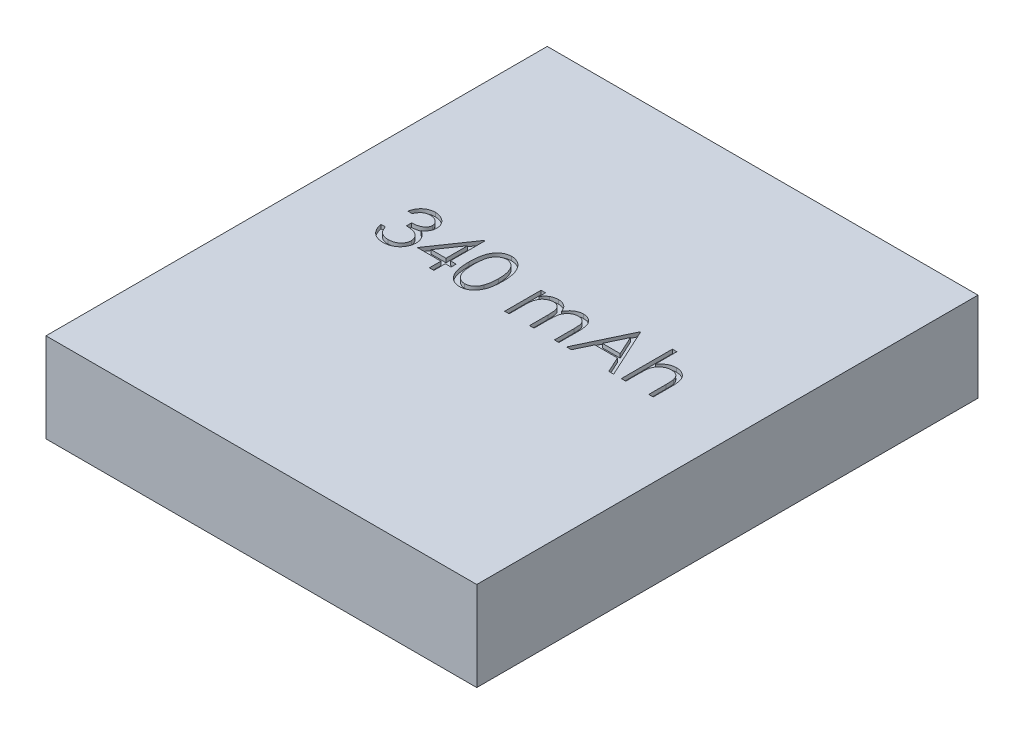
from build123d import *

# Parameters (mm, degrees)
SKETCH1_W           = 27.5
SKETCH1_H           = 32
BOSS_EXTRUDE1_DEPTH = 5.7
CUT_EXTRUDE1_DEPTH  = 0.254


with BuildPart() as part:
    # Sketch1 → Boss-Extrude1 (new body)
    with BuildSketch(Plane(origin=(0, 0, 0), x_dir=(1, 0, 0), z_dir=(0, 1, 0))):
        Rectangle(SKETCH1_W, SKETCH1_H)
    extrude(amount=BOSS_EXTRUDE1_DEPTH)

    # Sketch2 → Cut-Extrude1 (cut)
    with BuildSketch(Plane(origin=(0, 5.7, 0), x_dir=(1, 0, 0), z_dir=(0, 1, 0))):
        with BuildLine():
            Line((6.980929487, 3.256410256), (7.265865385, 3.256410256))
            Line((7.265865385, 3.256410256), (7.265865385, 1.881976162))
            add(Edge.make_bspline(
                [(7.265865385, 1.881976162), (7.296451794, 1.920206774), (7.3560051, 1.994643735), (7.456240863, 2.09176353), (7.559175154, 2.175945136), (7.668363232, 2.242956194), (7.781801918, 2.295893915), (7.899969653, 2.333438423), (8.022888391, 2.356526204), (8.106368348, 2.359427626), (8.148657853, 2.360897436)],
                knots=[0, 0, 0, 0, 0.000146744, 0.000285718, 0.000417826, 0.00054491, 0.000668979, 0.000792481, 0.000915983, 0.001042781, 0.001042781, 0.001042781, 0.001042781], degree=3))
            add(Edge.make_bspline(
                [(8.148657853, 2.360897436), (8.19159328, 2.359314081), (8.275628269, 2.356215074), (8.397985025, 2.331710079), (8.512249533, 2.289838689), (8.618082118, 2.232537173), (8.713173094, 2.16116968), (8.797401094, 2.078772513), (8.866199533, 1.98327403), (8.913007303, 1.895048714), (8.943463181, 1.816545701), (8.962741623, 1.749202579), (8.97908761, 1.674161987), (8.993329513, 1.591462551), (9.002821477, 1.500707288), (9.010445666, 1.402305643), (9.015867163, 1.296263257), (9.016077262, 1.222857031), (9.016185897, 1.184900841)],
                knots=[0, 0, 0, 0, 0.000128741, 0.000251978, 0.000372501, 0.000492599, 0.000611662, 0.000728143, 0.000844672, 0.000963309, 0.001026736, 0.001096978, 0.001173207, 0.001257065, 0.001348583, 0.001446826, 0.001553163, 0.001667017, 0.001667017, 0.001667017, 0.001667017], degree=3))
            Line((9.016185897, 1.184900841), (9.016185897, 0))
            Line((9.016185897, 0), (8.73125, 0))
            Line((8.73125, 0), (8.73125, 1.09140625))
            add(Edge.make_bspline(
                [(8.73125, 1.09140625), (8.731077368, 1.122995386), (8.730747152, 1.183420027), (8.729655546, 1.269930711), (8.727218765, 1.348395062), (8.723281016, 1.418561611), (8.71913963, 1.480528179), (8.713439764, 1.534204779), (8.706808337, 1.579665132), (8.700849514, 1.607028759), (8.698177083, 1.619300881)],
                knots=[0, 0, 0, 0, 9.4769e-05, 0.000181277, 0.000259548, 0.000330249, 0.000392103, 0.000445834, 0.000492159, 0.000529829, 0.000529829, 0.000529829, 0.000529829], degree=3))
            add(Edge.make_bspline(
                [(8.698177083, 1.619300881), (8.687813661, 1.655309249), (8.667890042, 1.724535126), (8.621582234, 1.818571741), (8.563743703, 1.898749328), (8.493125115, 1.96398586), (8.410975742, 2.015159185), (8.316759918, 2.050599245), (8.21136437, 2.072595393), (8.137113392, 2.074808189), (8.09841246, 2.075961538)],
                knots=[0, 0, 0, 0, 0.000112235, 0.000215771, 0.000312707, 0.000407219, 0.000502346, 0.000601207, 0.000707732, 0.000823699, 0.000823699, 0.000823699, 0.000823699], degree=3))
            add(Edge.make_bspline(
                [(8.09841246, 2.075961538), (8.07549098, 2.075529896), (8.030129963, 2.074675687), (7.962866531, 2.06609965), (7.897616595, 2.052085456), (7.833751762, 2.033122053), (7.772625575, 2.007317887), (7.712456309, 1.977445501), (7.654948705, 1.940880156), (7.599081571, 1.899853924), (7.54708638, 1.854433499), (7.498711069, 1.806493761), (7.455587003, 1.755444329), (7.416517638, 1.702104224), (7.382791622, 1.645741811), (7.35335204, 1.586900608), (7.32837323, 1.525503233), (7.315961073, 1.482890142), (7.309750601, 1.46156851)],
                knots=[0, 0, 0, 0, 6.8737e-05, 0.000136029, 0.000203016, 0.000268809, 0.000335543, 0.000401817, 0.000470111, 0.000539693, 0.000609577, 0.000677037, 0.000743816, 0.000809842, 0.000875179, 0.000940599, 0.001007093, 0.001073681, 0.001073681, 0.001073681, 0.001073681], degree=3))
            add(Edge.make_bspline(
                [(7.309750601, 1.46156851), (7.306176978, 1.446128076), (7.298389613, 1.412481469), (7.289939728, 1.356987618), (7.282376156, 1.292502124), (7.275982114, 1.219122793), (7.272060457, 1.136580738), (7.267834767, 1.045439225), (7.266261769, 0.945127349), (7.266001462, 0.875372139), (7.265865385, 0.838907252)],
                knots=[0, 0, 0, 0, 4.7531e-05, 0.000103577, 0.000168266, 0.000242318, 0.000324485, 0.000416151, 0.000516024, 0.000625421, 0.000625421, 0.000625421, 0.000625421], degree=3))
            Line((7.265865385, 0.838907252), (7.265865385, 0))
            Line((7.265865385, 0), (6.980929487, 0))
            Line((6.980929487, 0), (6.980929487, 3.256410256))
        make_face()
        Polygon((5.027083333, 3.175), (6.492467949, 0), (6.182727364, 0), (5.713346354, 1.017628205), (4.274038462, 1.017628205), (3.791301082, 0), (3.480288462, 0), (4.986378205, 3.175), align=None)
        Polygon((5.003550681, 2.556154848), (4.428590745, 1.343269231), (5.563246194, 1.343269231), align=None, mode=Mode.SUBTRACT)
        with BuildLine():
            Line((-0.468108974, 2.320192308), (-0.183173077, 2.320192308))
            Line((-0.183173077, 2.320192308), (-0.183173077, 1.916957131))
            add(Edge.make_bspline(
                [(-0.183173077, 1.916957131), (-0.157515494, 1.952233742), (-0.108353105, 2.019827109), (-0.027739263, 2.108899724), (0.052793354, 2.184490264), (0.110790064, 2.224171297), (0.138651843, 2.243234175)],
                knots=[0, 0, 0, 0, 0.000130766, 0.000250561, 0.000359957, 0.000461102, 0.000461102, 0.000461102, 0.000461102], degree=3))
            add(Edge.make_bspline(
                [(0.138651843, 2.243234175), (0.176629072, 2.261381899), (0.251920024, 2.297360285), (0.371136035, 2.333857871), (0.493123771, 2.35628707), (0.575499794, 2.359354459), (0.616937099, 2.360897436)],
                knots=[0, 0, 0, 0, 0.000126121, 0.000250038, 0.000372801, 0.000497059, 0.000497059, 0.000497059, 0.000497059], degree=3))
            add(Edge.make_bspline(
                [(0.616937099, 2.360897436), (0.644961461, 2.359949208), (0.700420164, 2.358072715), (0.782592875, 2.345862541), (0.862293187, 2.324756798), (0.939050199, 2.295358726), (1.011368244, 2.259756374), (1.077670588, 2.21798271), (1.137201119, 2.171086078), (1.189929752, 2.11694876), (1.237345225, 2.05405056), (1.280959607, 1.980695134), (1.321259621, 1.895235327), (1.343594665, 1.833217108), (1.355353566, 1.800565905)],
                knots=[0, 0, 0, 0, 8.4072e-05, 0.000166375, 0.000248601, 0.000330932, 0.000412566, 0.00049003, 0.000565619, 0.000639381, 0.000716086, 0.000801384, 0.000894984, 0.000999053, 0.000999053, 0.000999053, 0.000999053], degree=3))
            add(Edge.make_bspline(
                [(1.355353566, 1.800565905), (1.367791629, 1.822994486), (1.392267992, 1.867130782), (1.433366677, 1.929595063), (1.47642675, 1.988021224), (1.521815183, 2.042455623), (1.569371772, 2.09262945), (1.619320328, 2.13870859), (1.671376523, 2.180890926), (1.743759483, 2.230169792), (1.837932348, 2.282513007), (1.956666567, 2.327895953), (2.080174222, 2.355941298), (2.164010277, 2.359234474), (2.206345152, 2.360897436)],
                knots=[0, 0, 0, 0, 7.6916e-05, 0.00015136, 0.000224122, 0.000294562, 0.000363845, 0.000431358, 0.000498307, 0.000564639, 0.000693874, 0.000820499, 0.000944881, 0.001071761, 0.001071761, 0.001071761, 0.001071761], degree=3))
            add(Edge.make_bspline(
                [(2.206345152, 2.360897436), (2.245244765, 2.359430386), (2.321375084, 2.356559226), (2.432207318, 2.334013575), (2.535568813, 2.295298852), (2.631251589, 2.242472625), (2.717575134, 2.176088651), (2.792610643, 2.097104777), (2.85590233, 2.006079683), (2.897248667, 1.920452665), (2.925293228, 1.844855613), (2.942584491, 1.780442763), (2.9578605, 1.70954814), (2.970543487, 1.632086974), (2.979813173, 1.547785637), (2.986680894, 1.456782085), (2.99132916, 1.359005591), (2.991657612, 1.291545459), (2.991826923, 1.256770833)],
                knots=[0, 0, 0, 0, 0.000116641, 0.000228278, 0.000337557, 0.000446591, 0.000554977, 0.000662946, 0.000772158, 0.00088622, 0.000947188, 0.001013849, 0.001086078, 0.001164708, 0.001249203, 0.001340422, 0.00143847, 0.001542785, 0.001542785, 0.001542785, 0.001542785], degree=3))
            Line((2.991826923, 1.256770833), (2.991826923, 0))
            Line((2.991826923, 0), (2.706891026, 0))
            Line((2.706891026, 0), (2.706891026, 1.258042869))
            add(Edge.make_bspline(
                [(2.706891026, 1.258042869), (2.706820375, 1.287725104), (2.706684594, 1.344769845), (2.704241086, 1.426641711), (2.699637051, 1.501270864), (2.694253486, 1.568555544), (2.686775173, 1.628652659), (2.677117792, 1.681441496), (2.666887325, 1.727337311), (2.649891105, 1.778215368), (2.622724089, 1.834340488), (2.581342517, 1.894868303), (2.529208921, 1.947555886), (2.469010779, 1.993292502), (2.400477547, 2.030479591), (2.324944548, 2.057037114), (2.24288073, 2.073477153), (2.186072915, 2.075115467), (2.156735777, 2.075961538)],
                knots=[0, 0, 0, 0, 8.9045e-05, 0.00017113, 0.000245678, 0.000313338, 0.000373609, 0.000427253, 0.000474306, 0.000514531, 0.000587924, 0.000660612, 0.000733474, 0.000809288, 0.000886697, 0.000966359, 0.001048684, 0.001136601, 0.001136601, 0.001136601, 0.001136601], degree=3))
            add(Edge.make_bspline(
                [(2.156735777, 2.075961538), (2.120749461, 2.074676881), (2.049626821, 2.072137911), (1.945808415, 2.046217326), (1.846048993, 2.007137384), (1.753325265, 1.950502227), (1.668028627, 1.882640354), (1.594641153, 1.801950363), (1.534014813, 1.710664644), (1.492962992, 1.626167278), (1.467028411, 1.55026714), (1.449904352, 1.483957381), (1.436584418, 1.40859053), (1.424092581, 1.324673021), (1.415939428, 1.231627214), (1.408529547, 1.129883522), (1.405063479, 1.01913593), (1.404578648, 0.942367434), (1.404326923, 0.902509014)],
                knots=[0, 0, 0, 0, 0.000107758, 0.00021297, 0.000319147, 0.000428114, 0.000537576, 0.000645175, 0.000753838, 0.000865349, 0.000925892, 0.00099423, 0.001070573, 0.001155393, 0.001248678, 0.001350681, 0.001461413, 0.001580991, 0.001580991, 0.001580991, 0.001580991], degree=3))
            Line((1.404326923, 0.902509014), (1.404326923, 0))
            Line((1.404326923, 0), (1.119391026, 0))
            Line((1.119391026, 0), (1.119391026, 1.1798127))
            add(Edge.make_bspline(
                [(1.119391026, 1.1798127), (1.11931897, 1.213098782), (1.119180343, 1.277137859), (1.116752541, 1.368971264), (1.112138249, 1.452501958), (1.106803751, 1.527632857), (1.099129161, 1.59422742), (1.090411734, 1.652642665), (1.080116923, 1.702732146), (1.063071813, 1.757671788), (1.037023688, 1.818197197), (0.995124336, 1.882732266), (0.942866031, 1.939218326), (0.881569594, 1.987440905), (0.812621582, 2.027302106), (0.73643664, 2.056022023), (0.653700755, 2.072735486), (0.596661693, 2.074865908), (0.567327724, 2.075961538)],
                knots=[0, 0, 0, 0, 9.9857e-05, 0.000192114, 0.000275552, 0.00035082, 0.000418036, 0.000476595, 0.00052799, 0.000571244, 0.000648997, 0.000724854, 0.000800924, 0.000878799, 0.000958003, 0.00103892, 0.001121993, 0.00120995, 0.00120995, 0.00120995, 0.00120995], degree=3))
            add(Edge.make_bspline(
                [(0.567327724, 2.075961538), (0.53284159, 2.074573193), (0.464111948, 2.071806269), (0.363145161, 2.04690132), (0.265640291, 2.007890481), (0.173152814, 1.953770502), (0.08817698, 1.886733481), (0.013783766, 1.807889254), (-0.048756954, 1.718219059), (-0.090242243, 1.634612676), (-0.117001573, 1.560614063), (-0.134777341, 1.497702846), (-0.150053287, 1.427852621), (-0.161405293, 1.350847884), (-0.172363955, 1.267190177), (-0.177652879, 1.176462747), (-0.182797796, 1.078743425), (-0.183044915, 1.011276902), (-0.183173077, 0.976287059)],
                knots=[0, 0, 0, 0, 0.000103317, 0.000205907, 0.000310077, 0.000417526, 0.000526194, 0.000633726, 0.00074153, 0.00085303, 0.000912585, 0.000977409, 0.001049016, 0.001126918, 0.001210855, 0.001302028, 0.00139944, 0.001504391, 0.001504391, 0.001504391, 0.001504391], degree=3))
            Line((-0.183173077, 0.976287059), (-0.183173077, 0))
            Line((-0.183173077, 0), (-0.468108974, 0))
            Line((-0.468108974, 0), (-0.468108974, 2.320192308))
        make_face()
        with BuildLine():
            add(Edge.make_bspline(
                [(-4.335096154, 1.586227965), (-4.334798595, 1.637116309), (-4.334220581, 1.735967652), (-4.327790371, 1.880008006), (-4.317108453, 2.015136268), (-4.302469551, 2.141358907), (-4.284655097, 2.258708507), (-4.260873906, 2.366871466), (-4.233829435, 2.466348394), (-4.20248543, 2.557463681), (-4.167117936, 2.641444883), (-4.128624, 2.719844887), (-4.085475936, 2.792545069), (-4.040139736, 2.860705779), (-3.990780214, 2.923211273), (-3.938802026, 2.98094426), (-3.882176467, 3.032570441), (-3.822828452, 3.079602444), (-3.760220659, 3.120831607), (-3.696137669, 3.15714702), (-3.630138395, 3.188171185), (-3.562042643, 3.212564652), (-3.492462466, 3.232713063), (-3.421154626, 3.246491609), (-3.348001389, 3.25516109), (-3.298624302, 3.255989917), (-3.273582732, 3.256410256)],
                knots=[0, 0, 0, 0, 0.000152656, 0.000296537, 0.000432439, 0.000559218, 0.000677689, 0.000788344, 0.000891263, 0.000986803, 0.001077167, 0.001164489, 0.00124859, 0.001330617, 0.001409885, 0.001487322, 0.001563392, 0.001639481, 0.001714274, 0.001788036, 0.00186031, 0.001932743, 0.002004819, 0.002077414, 0.00215039, 0.002225483, 0.002225483, 0.002225483, 0.002225483], degree=3))
            add(Edge.make_bspline(
                [(-3.273582732, 3.256410256), (-3.248331977, 3.255967738), (-3.198116169, 3.255087709), (-3.123875257, 3.246629561), (-3.051349474, 3.232595043), (-2.98084802, 3.212709587), (-2.911791782, 3.188039223), (-2.844720898, 3.157117338), (-2.77921876, 3.121122937), (-2.716326285, 3.07882842), (-2.655353026, 3.031673069), (-2.59779666, 2.978366934), (-2.543651946, 2.91944826), (-2.492239348, 2.855547427), (-2.445017485, 2.785438814), (-2.4000473, 2.7103418), (-2.359795524, 2.628943087), (-2.321029069, 2.542600805), (-2.287567302, 2.448925915), (-2.257390066, 2.348446454), (-2.233007001, 2.239975584), (-2.212696733, 2.124082419), (-2.196962434, 2.000341345), (-2.185502823, 1.869017616), (-2.179449382, 1.730024833), (-2.178309374, 1.634994498), (-2.177724359, 1.586227965)],
                knots=[0, 0, 0, 0, 7.5729e-05, 0.000150601, 0.00022382, 0.00029712, 0.000370151, 0.00044358, 0.000518452, 0.000594128, 0.000670717, 0.000749483, 0.000829148, 0.000910598, 0.000995274, 0.001082536, 0.001172987, 0.001267529, 0.001366317, 0.00147116, 0.001582092, 0.001699622, 0.00182403, 0.001956183, 0.00209498, 0.002241286, 0.002241286, 0.002241286, 0.002241286], degree=3))
            add(Edge.make_bspline(
                [(-2.177724359, 1.586227965), (-2.178315439, 1.537674134), (-2.179467135, 1.443068975), (-2.185434962, 1.30470159), (-2.197190292, 1.174074794), (-2.211895067, 1.050875303), (-2.232261297, 0.935615891), (-2.257303127, 0.827897713), (-2.285107348, 0.727255591), (-2.319428911, 0.634514012), (-2.356994342, 0.548379235), (-2.397865841, 0.467945464), (-2.441653469, 0.392501756), (-2.489358973, 0.322651986), (-2.540207427, 0.257901347), (-2.595287135, 0.199392789), (-2.653045452, 0.145716537), (-2.714198143, 0.097953989), (-2.778071479, 0.056148487), (-2.843348641, 0.018761637), (-2.911187853, -0.011385165), (-2.980051746, -0.037270523), (-3.050925336, -0.057046647), (-3.123720276, -0.070720788), (-3.19806629, -0.080310965), (-3.248323424, -0.081042557), (-3.273582732, -0.081410256)],
                knots=[0, 0, 0, 0, 0.00014567, 0.000283833, 0.000415351, 0.000539048, 0.000655953, 0.000766265, 0.000870752, 0.000968942, 0.001062646, 0.001152529, 0.001239469, 0.001324145, 0.001406093, 0.001486191, 0.001564957, 0.001642439, 0.001718644, 0.001793826, 0.001867834, 0.001941084, 0.002014383, 0.002088227, 0.002163172, 0.002238901, 0.002238901, 0.002238901, 0.002238901], degree=3))
            add(Edge.make_bspline(
                [(-3.273582732, -0.081410256), (-3.298623607, -0.080987205), (-3.347999325, -0.080153031), (-3.421162596, -0.071522718), (-3.492175956, -0.057647511), (-3.561389825, -0.038219592), (-3.629159307, -0.01443899), (-3.694560938, 0.01654328), (-3.758321909, 0.052224899), (-3.820272106, 0.092860746), (-3.879247423, 0.139416844), (-3.93557973, 0.190910163), (-3.987853854, 0.248625686), (-4.036507641, 0.311652088), (-4.082748421, 0.379409529), (-4.125283781, 0.452823125), (-4.164627341, 0.531601779), (-4.200589651, 0.616254455), (-4.23247451, 0.708016425), (-4.260639217, 0.807937466), (-4.282877059, 0.916899507), (-4.301911597, 1.034027404), (-4.317264431, 1.15982447), (-4.327745854, 1.294358997), (-4.334224047, 1.437547151), (-4.334800147, 1.535763303), (-4.335096154, 1.586227965)],
                knots=[0, 0, 0, 0, 7.5093e-05, 0.000148069, 0.000220664, 0.000291955, 0.000363574, 0.000435848, 0.000508744, 0.000582656, 0.000657851, 0.000733921, 0.000811359, 0.000891128, 0.000972628, 0.001057278, 0.001145453, 0.00123665, 0.001333, 0.001436702, 0.001547845, 0.001666417, 0.001792639, 0.001927908, 0.002071153, 0.002222537, 0.002222537, 0.002222537, 0.002222537], degree=3))
        make_face()
        with BuildLine():
            add(Edge.make_bspline(
                [(-4.050160256, 1.5875), (-4.050051901, 1.545092252), (-4.049841604, 1.46278714), (-4.044347765, 1.343186467), (-4.036863626, 1.231634812), (-4.027210449, 1.127990532), (-4.012874917, 1.03260445), (-3.996812331, 0.944820523), (-3.977265136, 0.865103315), (-3.954137512, 0.792905801), (-3.927794903, 0.727002717), (-3.899033155, 0.665678758), (-3.868135214, 0.608209501), (-3.833555699, 0.555111156), (-3.795895605, 0.506210565), (-3.756005578, 0.46064221), (-3.712396876, 0.420004948), (-3.652068481, 0.371267015), (-3.572424536, 0.32090323), (-3.472075981, 0.27704642), (-3.368962457, 0.249485191), (-3.298975252, 0.245980213), (-3.264042468, 0.244230769)],
                knots=[0, 0, 0, 0, 0.00012721, 0.000246889, 0.000359088, 0.000462625, 0.000559048, 0.000648362, 0.000730273, 0.000805096, 0.000875606, 0.000943038, 0.001008214, 0.001071192, 0.001132889, 0.001193261, 0.001252653, 0.001311456, 0.001425798, 0.001534033, 0.001639084, 0.00174377, 0.00174377, 0.00174377, 0.00174377], degree=3))
            add(Edge.make_bspline(
                [(-3.264042468, 0.244230769), (-3.228883723, 0.245680185), (-3.158638823, 0.248576023), (-3.056010308, 0.276514878), (-2.956378563, 0.318669388), (-2.878299018, 0.368514626), (-2.818896996, 0.415983896), (-2.776336584, 0.456455755), (-2.737273154, 0.501772864), (-2.700223557, 0.550667225), (-2.666242825, 0.604072978), (-2.635342692, 0.661733315), (-2.607145656, 0.723808354), (-2.591081021, 0.767142332), (-2.582867588, 0.789297877)],
                knots=[0, 0, 0, 0, 0.000105268, 0.000210319, 0.000316882, 0.000428931, 0.00048684, 0.000544871, 0.000604822, 0.000666135, 0.000728769, 0.000794503, 0.000862248, 0.000933117, 0.000933117, 0.000933117, 0.000933117], degree=3))
            add(Edge.make_bspline(
                [(-2.582867588, 0.789297877), (-2.573295627, 0.817627712), (-2.553860442, 0.875149426), (-2.528812618, 0.964379311), (-2.509086435, 1.057998961), (-2.491339667, 1.155448888), (-2.479226538, 1.25744776), (-2.469476736, 1.36367998), (-2.463733898, 1.474225644), (-2.463022017, 1.549332529), (-2.462660256, 1.5875)],
                knots=[0, 0, 0, 0, 8.9703e-05, 0.000182136, 0.00027782, 0.000376635, 0.000479189, 0.000585832, 0.000696647, 0.000811146, 0.000811146, 0.000811146, 0.000811146], degree=3))
            add(Edge.make_bspline(
                [(-2.462660256, 1.5875), (-2.463159357, 1.625661298), (-2.464135703, 1.700312955), (-2.467867678, 1.809640161), (-2.477504778, 1.913478773), (-2.488208264, 2.01227613), (-2.503990029, 2.105485333), (-2.521006039, 2.193886682), (-2.543867139, 2.276384997), (-2.568287221, 2.354271903), (-2.596236651, 2.426662497), (-2.627003067, 2.493894289), (-2.659861377, 2.556291861), (-2.695550409, 2.613684015), (-2.733646493, 2.666327822), (-2.775155127, 2.713167775), (-2.818429808, 2.755655596), (-2.879042541, 2.804153784), (-2.958394218, 2.853603679), (-3.05713277, 2.89911119), (-3.159885426, 2.925244427), (-3.229348487, 2.928928957), (-3.264042468, 2.930769231)],
                knots=[0, 0, 0, 0, 0.000114499, 0.000223985, 0.000328037, 0.000427282, 0.000522015, 0.000611574, 0.0006972, 0.000778663, 0.000856382, 0.000929811, 0.001000372, 0.00106779, 0.001132413, 0.001195057, 0.001255328, 0.001314131, 0.001427596, 0.001534925, 0.001639202, 0.001743255, 0.001743255, 0.001743255, 0.001743255], degree=3))
            add(Edge.make_bspline(
                [(-3.264042468, 2.930769231), (-3.299158505, 2.928926418), (-3.369454552, 2.925237437), (-3.473275197, 2.899208557), (-3.572792716, 2.853839652), (-3.651934557, 2.80399), (-3.712589564, 2.756511674), (-3.755300293, 2.715339677), (-3.795347177, 2.670303432), (-3.832238591, 2.620953123), (-3.866791012, 2.567916683), (-3.898523788, 2.510776875), (-3.927114508, 2.449244137), (-3.953498338, 2.383370657), (-3.97669651, 2.311179371), (-3.995831748, 2.231560356), (-4.013509289, 2.144055639), (-4.026023568, 2.048152943), (-4.037148547, 1.944482704), (-4.044298055, 1.832652565), (-4.049859982, 1.712851306), (-4.05005816, 1.630120641), (-4.050160256, 1.5875)],
                knots=[0, 0, 0, 0, 0.00010532, 0.000210832, 0.000318741, 0.000432206, 0.000490612, 0.000549543, 0.000609914, 0.000671226, 0.000734205, 0.000799687, 0.00086712, 0.000937629, 0.001012452, 0.001094363, 0.001183173, 0.001280136, 0.001384369, 0.001495934, 0.001616249, 0.001744095, 0.001744095, 0.001744095, 0.001744095], degree=3))
        make_face(mode=Mode.SUBTRACT)
        Polygon((-5.044255809, 3.256410256), (-4.986378205, 3.256410256), (-4.986378205, 1.058333333), (-4.620032051, 1.058333333), (-4.620032051, 0.732692308), (-4.986378205, 0.732692308), (-4.986378205, 0), (-5.271314103, 0), (-5.271314103, 0.732692308), (-6.777403846, 0.732692308), align=None)
        Polygon((-5.271314103, 1.058333333), (-5.271314103, 2.437219551), (-6.217708333, 1.058333333), align=None, mode=Mode.SUBTRACT)
        with BuildLine():
            Line((-8.812660256, 2.442307692), (-9.097596154, 2.442307692))
            add(Edge.make_bspline(
                [(-9.097596154, 2.442307692), (-9.089876776, 2.474268588), (-9.074786023, 2.536749526), (-9.043310367, 2.62601897), (-9.009021043, 2.710495307), (-8.967846641, 2.788596746), (-8.922935128, 2.861892893), (-8.871479516, 2.928721313), (-8.815853768, 2.990781646), (-8.75432685, 3.045857226), (-8.689802992, 3.09572988), (-8.621373016, 3.138252254), (-8.550413676, 3.174832021), (-8.476433334, 3.204967517), (-8.399211736, 3.227669242), (-8.319447006, 3.244140059), (-8.236930117, 3.254836284), (-8.180916231, 3.25588019), (-8.152473958, 3.256410256)],
                knots=[0, 0, 0, 0, 9.8575e-05, 0.000192705, 0.000283656, 0.000371842, 0.000457261, 0.000541217, 0.000624516, 0.000706917, 0.000788585, 0.000868879, 0.000948242, 0.001027846, 0.001108138, 0.001189341, 0.001272016, 0.001357302, 0.001357302, 0.001357302, 0.001357302], degree=3))
            add(Edge.make_bspline(
                [(-8.152473958, 3.256410256), (-8.111033185, 3.255159098), (-8.029055582, 3.252684071), (-7.908620533, 3.230083118), (-7.792481918, 3.194318891), (-7.681910958, 3.144903438), (-7.579205665, 3.083954947), (-7.487823553, 3.011415507), (-7.409003261, 2.928684712), (-7.342877647, 2.837305886), (-7.291102469, 2.73964696), (-7.252924116, 2.639135389), (-7.229681591, 2.5360096), (-7.226669372, 2.466379783), (-7.225160256, 2.431495393)],
                knots=[0, 0, 0, 0, 0.000124221, 0.000245732, 0.000366235, 0.000488093, 0.000608186, 0.000723607, 0.000836972, 0.000949947, 0.001060913, 0.001167586, 0.001271755, 0.001376341, 0.001376341, 0.001376341, 0.001376341], degree=3))
            add(Edge.make_bspline(
                [(-7.225160256, 2.431495393), (-7.2262158, 2.397924943), (-7.228281334, 2.332232783), (-7.245819767, 2.236328282), (-7.275334806, 2.145939116), (-7.316219519, 2.060684776), (-7.369143639, 1.981105814), (-7.433253871, 1.907023185), (-7.509002715, 1.838108306), (-7.566405751, 1.798629927), (-7.595958534, 1.778305288)],
                knots=[0, 0, 0, 0, 0.000100654, 0.000196964, 0.000291294, 0.000385168, 0.000479719, 0.000577128, 0.000678438, 0.000785942, 0.000785942, 0.000785942, 0.000785942], degree=3))
            add(Edge.make_bspline(
                [(-7.595958534, 1.778305288), (-7.562184013, 1.761996519), (-7.49526692, 1.729684128), (-7.404053226, 1.666314977), (-7.321251153, 1.593148148), (-7.275074208, 1.53605017), (-7.251872997, 1.507361779)],
                knots=[0, 0, 0, 0, 0.000112361, 0.00022262, 0.000332061, 0.000442576, 0.000442576, 0.000442576, 0.000442576], degree=3))
            add(Edge.make_bspline(
                [(-7.251872997, 1.507361779), (-7.236595493, 1.486445104), (-7.206290666, 1.44495428), (-7.168884146, 1.378246236), (-7.134948735, 1.310798814), (-7.108505322, 1.24080421), (-7.0880276, 1.16907369), (-7.073389914, 1.095484088), (-7.064296586, 1.019975311), (-7.062994335, 0.968891847), (-7.062339744, 0.943214143)],
                knots=[0, 0, 0, 0, 7.7636e-05, 0.000154, 0.000229094, 0.000303982, 0.000378066, 0.000452657, 0.000528865, 0.000605889, 0.000605889, 0.000605889, 0.000605889], degree=3))
            add(Edge.make_bspline(
                [(-7.062339744, 0.943214143), (-7.063967624, 0.898755324), (-7.067215723, 0.810046911), (-7.096247991, 0.678987699), (-7.141254287, 0.550875994), (-7.205168794, 0.428343818), (-7.283062891, 0.313698758), (-7.375734178, 0.211122392), (-7.482129705, 0.122949372), (-7.600789116, 0.049280094), (-7.729346796, -0.009609735), (-7.866847512, -0.050483273), (-8.011310061, -0.077104287), (-8.110376681, -0.079958946), (-8.160742188, -0.081410256)],
                knots=[0, 0, 0, 0, 0.000133226, 0.000265824, 0.000400805, 0.00053962, 0.000679164, 0.000815599, 0.000952897, 0.001092317, 0.00123349, 0.001375737, 0.001521711, 0.001672674, 0.001672674, 0.001672674, 0.001672674], degree=3))
            add(Edge.make_bspline(
                [(-8.160742188, -0.081410256), (-8.194686838, -0.080622663), (-8.261478592, -0.079072942), (-8.359670909, -0.068478782), (-8.45339845, -0.04912942), (-8.542787943, -0.023091422), (-8.627918797, 0.009921087), (-8.708531235, 0.05103162), (-8.78512121, 0.099392769), (-8.856965973, 0.155575381), (-8.924056959, 0.218423453), (-8.984611216, 0.289052698), (-9.039638314, 0.366157486), (-9.087664851, 0.450633401), (-9.130878372, 0.541388741), (-9.166421097, 0.639585593), (-9.197704434, 0.744346099), (-9.212249077, 0.817350906), (-9.219711538, 0.854807692)],
                knots=[0, 0, 0, 0, 0.000101834, 0.000200376, 0.000295798, 0.00038858, 0.000479406, 0.000569289, 0.000659631, 0.000750724, 0.000842509, 0.00093495, 0.001029366, 0.001126242, 0.001226104, 0.001330545, 0.001439228, 0.001553746, 0.001553746, 0.001553746, 0.001553746], degree=3))
            Line((-9.219711538, 0.854807692), (-8.934775641, 0.854807692))
            add(Edge.make_bspline(
                [(-8.934775641, 0.854807692), (-8.927352227, 0.830361087), (-8.912913041, 0.782810317), (-8.888334642, 0.714375183), (-8.860332709, 0.651638949), (-8.830293074, 0.594141403), (-8.798744055, 0.541316295), (-8.763442659, 0.494560456), (-8.727003506, 0.451820237), (-8.699535807, 0.427740482), (-8.686092748, 0.415955529)],
                knots=[0, 0, 0, 0, 7.6642e-05, 0.000149076, 0.00021798, 0.000282557, 0.000343641, 0.000402283, 0.000458165, 0.000511731, 0.000511731, 0.000511731, 0.000511731], degree=3))
            add(Edge.make_bspline(
                [(-8.686092748, 0.415955529), (-8.668315854, 0.402250112), (-8.632816938, 0.374881583), (-8.574970043, 0.339955106), (-8.514132611, 0.30969189), (-8.448986442, 0.286574537), (-8.380937329, 0.267000516), (-8.308885362, 0.254191188), (-8.233466215, 0.245402633), (-8.181969744, 0.244627088), (-8.155654046, 0.244230769)],
                knots=[0, 0, 0, 0, 6.7292e-05, 0.000134376, 0.000202358, 0.000270771, 0.000341449, 0.00041455, 0.000490054, 0.000568961, 0.000568961, 0.000568961, 0.000568961], degree=3))
            add(Edge.make_bspline(
                [(-8.155654046, 0.244230769), (-8.125941941, 0.244789483), (-8.067842482, 0.245882), (-7.983065574, 0.255929249), (-7.902413818, 0.270561838), (-7.826782664, 0.293161472), (-7.755181418, 0.321084102), (-7.688613779, 0.356143727), (-7.626205882, 0.397277867), (-7.568757065, 0.444031247), (-7.517099354, 0.495213603), (-7.471615653, 0.548746889), (-7.432948996, 0.604405392), (-7.401758178, 0.662497116), (-7.377128751, 0.722781502), (-7.360361847, 0.785427726), (-7.348703687, 0.849923103), (-7.34775426, 0.893764382), (-7.347275641, 0.915865385)],
                knots=[0, 0, 0, 0, 8.9099e-05, 0.000174226, 0.000255805, 0.000334697, 0.000410639, 0.000486028, 0.00055994, 0.000634539, 0.000707846, 0.0007778, 0.000845016, 0.000910751, 0.000975237, 0.001039889, 0.001105031, 0.001171253, 0.001171253, 0.001171253, 0.001171253], degree=3))
            add(Edge.make_bspline(
                [(-7.347275641, 0.915865385), (-7.348663843, 0.945448528), (-7.35143334, 1.004467612), (-7.372577551, 1.091297126), (-7.407356378, 1.174956936), (-7.456045013, 1.254019688), (-7.515313853, 1.327294971), (-7.584587733, 1.392674101), (-7.664441911, 1.446621969), (-7.737938507, 1.483895251), (-7.803039756, 1.509328883), (-7.858752283, 1.526269744), (-7.921124345, 1.540614988), (-7.989401676, 1.55396112), (-8.064098736, 1.565319772), (-8.145134205, 1.574791991), (-8.232524503, 1.582371206), (-8.293022918, 1.585755843), (-8.324198718, 1.5875)],
                knots=[0, 0, 0, 0, 8.8683e-05, 0.000176924, 0.000266456, 0.0003595, 0.00045446, 0.000548507, 0.000644124, 0.00074254, 0.000795099, 0.000853644, 0.000917048, 0.000987025, 0.001062314, 0.00114365, 0.001231751, 0.001325421, 0.001325421, 0.001325421, 0.001325421], degree=3))
            Line((-8.324198718, 1.5875), (-8.324198718, 1.913141026))
            add(Edge.make_bspline(
                [(-8.324198718, 1.913141026), (-8.284918375, 1.913807598), (-8.207977832, 1.915113248), (-8.095587998, 1.930904801), (-7.988115779, 1.95274937), (-7.887942949, 1.986209509), (-7.796640188, 2.025071778), (-7.717428834, 2.070294854), (-7.651418636, 2.120563948), (-7.598930379, 2.176654958), (-7.55944315, 2.23681218), (-7.530571698, 2.299510862), (-7.513517116, 2.365300546), (-7.51124049, 2.41019928), (-7.510096154, 2.432767428)],
                knots=[0, 0, 0, 0, 0.000117747, 0.000230638, 0.000339915, 0.000446313, 0.000546864, 0.000637192, 0.000719248, 0.000794851, 0.00086647, 0.000934214, 0.001001162, 0.001068823, 0.001068823, 0.001068823, 0.001068823], degree=3))
            add(Edge.make_bspline(
                [(-7.510096154, 2.432767428), (-7.510472084, 2.449347954), (-7.511219979, 2.482334124), (-7.520651795, 2.53052615), (-7.534825032, 2.577244866), (-7.554310215, 2.622291594), (-7.580390752, 2.665353913), (-7.611601897, 2.706798956), (-7.648765817, 2.746390099), (-7.691352044, 2.78329296), (-7.737082753, 2.818462197), (-7.787202191, 2.848319567), (-7.840199178, 2.873851159), (-7.896132386, 2.894905493), (-7.955183331, 2.910743562), (-8.017074566, 2.922115361), (-8.081924107, 2.929225234), (-8.126167036, 2.930248868), (-8.148657853, 2.930769231)],
                knots=[0, 0, 0, 0, 4.9675e-05, 9.8825e-05, 0.000146708, 0.000195982, 0.000245612, 0.000297384, 0.000351382, 0.000408162, 0.000466295, 0.000524214, 0.000582814, 0.00064259, 0.000703225, 0.000765972, 0.000831222, 0.000898688, 0.000898688, 0.000898688, 0.000898688], degree=3))
            add(Edge.make_bspline(
                [(-8.148657853, 2.930769231), (-8.184809009, 2.929507067), (-8.255420624, 2.927041767), (-8.357215585, 2.905449033), (-8.451848123, 2.870997486), (-8.524182485, 2.829873961), (-8.577597392, 2.789278925), (-8.615767186, 2.753825617), (-8.653250791, 2.714425841), (-8.687582227, 2.668652887), (-8.722302191, 2.619606584), (-8.753911187, 2.564793673), (-8.784626765, 2.505643972), (-8.803134792, 2.463828647), (-8.812660256, 2.442307692)],
                knots=[0, 0, 0, 0, 0.000108349, 0.000211631, 0.000310638, 0.000409485, 0.000459859, 0.000511627, 0.000565625, 0.000622746, 0.000683084, 0.000745805, 0.000812368, 0.000882955, 0.000882955, 0.000882955, 0.000882955], degree=3))
        make_face()
    extrude(amount=-CUT_EXTRUDE1_DEPTH, mode=Mode.SUBTRACT)


solid = part.part
